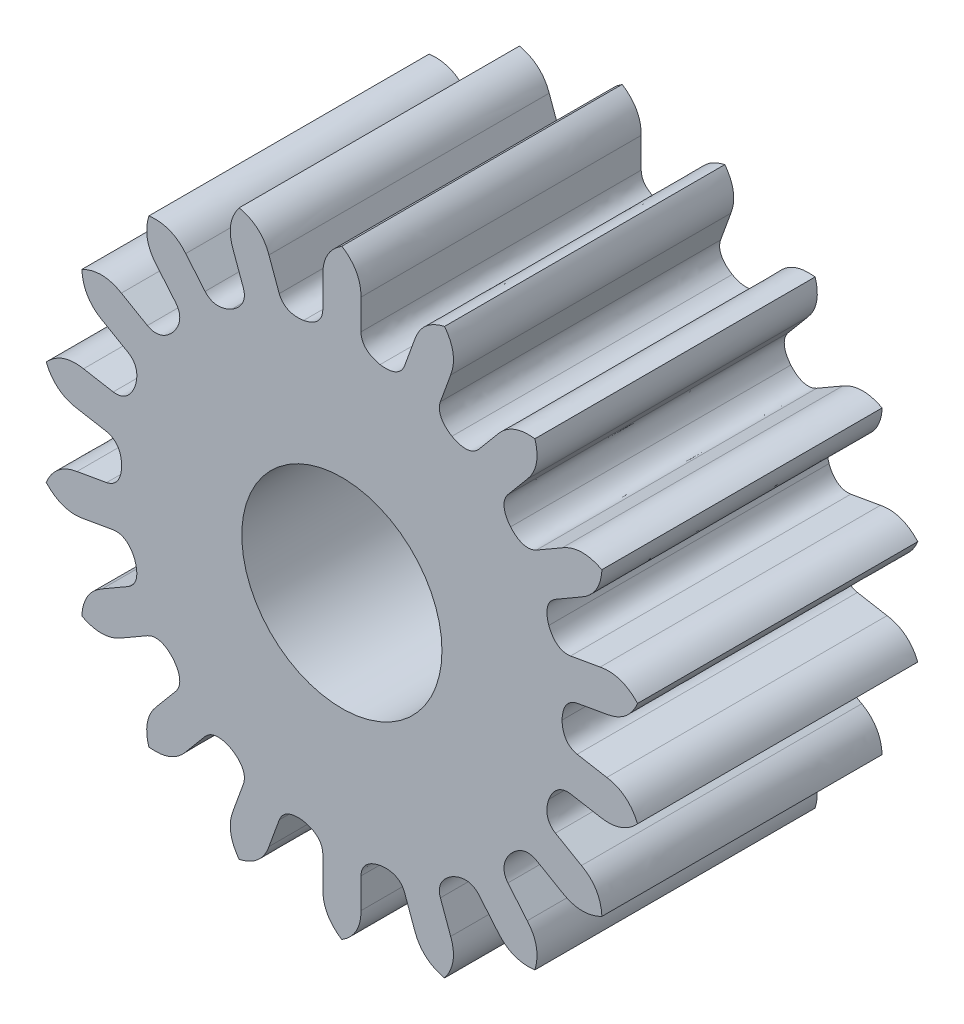
from build123d import *

# Parameters (mm, degrees)
BOSS_EXTRUDE1_18_TEETH_DEPTH = 1.4
CUT_EXTRUDE1_REACH           = 4.528
SKETCH2_R                    = 0.5


with BuildPart() as part:
    # Sketch1 → Boss-Extrude1 (18 teeth) (new body)
    with BuildSketch(Plane.XY):
        with BuildLine():
            Line((0.09535, 1.327125831), (0.09535, 1.176725832))
            add(Edge.make_bspline(
                [(0.09535, 1.176725832), (0.096898769, 1.121704145), (0.139449252, 1.093426583), (0.191012995, 1.083288528)],
                knots=[0, 0, 0, 0, 1, 1, 1, 1], degree=3))
            add(Edge.make_bspline(
                [(0.312864246, 1.138372202), (0.292590354, 1.087198438), (0.242934483, 1.075179344), (0.191012995, 1.083288528)],
                knots=[0, 0, 0, 0, 1, 1, 1, 1], degree=3))
            Line((0.312864246, 1.138372202), (0.364304075, 1.27970197))
            add(Edge.make_bspline(
                [(0.513010563, 1.409484937), (0.400738109, 1.383654504), (0.364304075, 1.27970197)],
                knots=[0, 0, 0, 1, 1, 1], degree=2))
            add(Edge.make_bspline(
                [(0.513010563, 1.409484937), (0.58241277, 1.317530335), (0.543503458, 1.214478729)],
                knots=[0, 0, 0, 1, 1, 1], degree=2))
            Line((0.543503458, 1.214478729), (0.492063629, 1.073148961))
            add(Edge.make_bspline(
                [(0.492063629, 1.073148961), (0.47470047, 1.020915777), (0.505013349, 0.979790438), (0.55, 0.952627944)],
                knots=[0, 0, 0, 0, 1, 1, 1, 1], degree=3))
            add(Edge.make_bspline(
                [(0.683342447, 0.962714083), (0.646788763, 0.921560555), (0.596016735, 0.927249609), (0.55, 0.952627944)],
                knots=[0, 0, 0, 0, 1, 1, 1, 1], degree=3))
            Line((0.683342447, 0.962714083), (0.780017703, 1.077927166))
            add(Edge.make_bspline(
                [(0.964144481, 1.149022649), (0.849808356, 1.163149422), (0.780017703, 1.077927166)],
                knots=[0, 0, 0, 1, 1, 1], degree=2))
            add(Edge.make_bspline(
                [(0.964144481, 1.149022649), (0.997910896, 1.038876635), (0.926102378, 0.955347569)],
                knots=[0, 0, 0, 1, 1, 1], degree=2))
            Line((0.926102378, 0.955347569), (0.829427123, 0.840134486))
            add(Edge.make_bspline(
                [(0.829427123, 0.840134486), (0.795246289, 0.796989899), (0.809665384, 0.747977106), (0.842648887, 0.707066371)],
                knots=[0, 0, 0, 0, 1, 1, 1, 1], degree=3))
            add(Edge.make_bspline(
                [(0.971399464, 0.670938438), (0.9229749, 0.644768868), (0.877210572, 0.667479886), (0.842648887, 0.707066371)],
                knots=[0, 0, 0, 0, 1, 1, 1, 1], degree=3))
            Line((0.971399464, 0.670938438), (1.101649683, 0.746138438))
            add(Edge.make_bspline(
                [(1.298988345, 0.749971271), (1.196379173, 0.802351353), (1.101649683, 0.746138438)],
                knots=[0, 0, 0, 1, 1, 1], degree=2))
            add(Edge.make_bspline(
                [(1.298988345, 0.749971271), (1.293046241, 0.63491908), (1.196999683, 0.580987393)],
                knots=[0, 0, 0, 1, 1, 1], degree=2))
            Line((1.196999683, 0.580987393), (1.066749464, 0.505787394))
            add(Edge.make_bspline(
                [(1.066749464, 0.505787394), (1.019873669, 0.476935277), (1.016659824, 0.425946697), (1.033661883, 0.376222158)],
                knots=[0, 0, 0, 0, 1, 1, 1, 1], degree=3))
            add(Edge.make_bspline(
                [(1.142291369, 0.298237716), (1.087836644, 0.290208539), (1.052599867, 0.327202238), (1.033661883, 0.376222158)],
                knots=[0, 0, 0, 0, 1, 1, 1, 1], degree=3))
            Line((1.142291369, 0.298237716), (1.290406453, 0.324354401))
            add(Edge.make_bspline(
                [(1.477155044, 0.260462289), (1.398649005, 0.344777869), (1.290406453, 0.324354401)],
                knots=[0, 0, 0, 1, 1, 1], degree=2))
            add(Edge.make_bspline(
                [(1.477155044, 0.260462289), (1.432221125, 0.154380914), (1.323521161, 0.136551563)],
                knots=[0, 0, 0, 1, 1, 1], degree=2))
            Line((1.323521161, 0.136551563), (1.175406077, 0.110434877))
            add(Edge.make_bspline(
                [(1.175406077, 0.110434877), (1.121489233, 0.099355222), (1.101030084, 0.052540829), (1.1, 0)],
                knots=[0, 0, 0, 0, 1, 1, 1, 1], degree=3))
            add(Edge.make_bspline(
                [(1.175406077, -0.110434877), (1.121489233, -0.099355222), (1.101030084, -0.052540829), (1.1, 0)],
                knots=[0, 0, 0, 0, 1, 1, 1, 1], degree=3))
            Line((1.175406077, -0.110434877), (1.323521161, -0.136551563))
            add(Edge.make_bspline(
                [(1.477155044, -0.260462289), (1.432221125, -0.154380914), (1.323521161, -0.136551563)],
                knots=[0, 0, 0, 1, 1, 1], degree=2))
            add(Edge.make_bspline(
                [(1.477155044, -0.260462289), (1.398649005, -0.344777869), (1.290406453, -0.324354401)],
                knots=[0, 0, 0, 1, 1, 1], degree=2))
            Line((1.290406453, -0.324354401), (1.142291369, -0.298237716))
            add(Edge.make_bspline(
                [(1.142291369, -0.298237716), (1.087836644, -0.290208539), (1.052599867, -0.327202238), (1.033661883, -0.376222158)],
                knots=[0, 0, 0, 0, 1, 1, 1, 1], degree=3))
            add(Edge.make_bspline(
                [(1.066749464, -0.505787394), (1.019873669, -0.476935277), (1.016659824, -0.425946697), (1.033661883, -0.376222158)],
                knots=[0, 0, 0, 0, 1, 1, 1, 1], degree=3))
            Line((1.066749464, -0.505787394), (1.196999683, -0.580987393))
            add(Edge.make_bspline(
                [(1.298988345, -0.749971271), (1.293046241, -0.63491908), (1.196999683, -0.580987393)],
                knots=[0, 0, 0, 1, 1, 1], degree=2))
            add(Edge.make_bspline(
                [(1.298988345, -0.749971271), (1.196379173, -0.802351353), (1.101649683, -0.746138438)],
                knots=[0, 0, 0, 1, 1, 1], degree=2))
            Line((1.101649683, -0.746138438), (0.971399464, -0.670938438))
            add(Edge.make_bspline(
                [(0.971399464, -0.670938438), (0.9229749, -0.644768868), (0.877210572, -0.667479886), (0.842648887, -0.707066371)],
                knots=[0, 0, 0, 0, 1, 1, 1, 1], degree=3))
            add(Edge.make_bspline(
                [(0.829427123, -0.840134486), (0.795246289, -0.796989899), (0.809665384, -0.747977106), (0.842648887, -0.707066371)],
                knots=[0, 0, 0, 0, 1, 1, 1, 1], degree=3))
            Line((0.829427123, -0.840134486), (0.926102378, -0.955347569))
            add(Edge.make_bspline(
                [(0.964144481, -1.149022649), (0.997910896, -1.038876635), (0.926102378, -0.955347569)],
                knots=[0, 0, 0, 1, 1, 1], degree=2))
            add(Edge.make_bspline(
                [(0.964144481, -1.149022649), (0.849808356, -1.163149422), (0.780017703, -1.077927166)],
                knots=[0, 0, 0, 1, 1, 1], degree=2))
            Line((0.780017703, -1.077927166), (0.683342447, -0.962714083))
            add(Edge.make_bspline(
                [(0.683342447, -0.962714083), (0.646788763, -0.921560555), (0.596016735, -0.927249609), (0.55, -0.952627944)],
                knots=[0, 0, 0, 0, 1, 1, 1, 1], degree=3))
            add(Edge.make_bspline(
                [(0.492063629, -1.073148961), (0.47470047, -1.020915777), (0.505013349, -0.979790438), (0.55, -0.952627944)],
                knots=[0, 0, 0, 0, 1, 1, 1, 1], degree=3))
            Line((0.492063629, -1.073148961), (0.543503458, -1.214478729))
            add(Edge.make_bspline(
                [(0.513010563, -1.409484937), (0.58241277, -1.317530335), (0.543503458, -1.214478729)],
                knots=[0, 0, 0, 1, 1, 1], degree=2))
            add(Edge.make_bspline(
                [(0.513010563, -1.409484937), (0.400738109, -1.383654504), (0.364304075, -1.27970197)],
                knots=[0, 0, 0, 1, 1, 1], degree=2))
            Line((0.364304075, -1.27970197), (0.312864246, -1.138372202))
            add(Edge.make_bspline(
                [(0.312864246, -1.138372202), (0.292590354, -1.087198438), (0.242934483, -1.075179344), (0.191012995, -1.083288528)],
                knots=[0, 0, 0, 0, 1, 1, 1, 1], degree=3))
            add(Edge.make_bspline(
                [(0.09535, -1.176725832), (0.096898769, -1.121704145), (0.139449252, -1.093426583), (0.191012995, -1.083288528)],
                knots=[0, 0, 0, 0, 1, 1, 1, 1], degree=3))
            Line((0.09535, -1.176725832), (0.09535, -1.327125831))
            add(Edge.make_bspline(
                [(0, -1.499942541), (0.096667068, -1.437270433), (0.09535, -1.327125831)],
                knots=[0, 0, 0, 1, 1, 1], degree=2))
            add(Edge.make_bspline(
                [(0, -1.499942541), (-0.096667068, -1.437270433), (-0.09535, -1.327125831)],
                knots=[0, 0, 0, 1, 1, 1], degree=2))
            Line((-0.09535, -1.327125831), (-0.09535, -1.176725832))
            add(Edge.make_bspline(
                [(-0.09535, -1.176725832), (-0.096898769, -1.121704145), (-0.139449252, -1.093426583), (-0.191012995, -1.083288528)],
                knots=[0, 0, 0, 0, 1, 1, 1, 1], degree=3))
            add(Edge.make_bspline(
                [(-0.312864246, -1.138372202), (-0.292590354, -1.087198438), (-0.242934483, -1.075179344), (-0.191012995, -1.083288528)],
                knots=[0, 0, 0, 0, 1, 1, 1, 1], degree=3))
            Line((-0.312864246, -1.138372202), (-0.364304075, -1.27970197))
            add(Edge.make_bspline(
                [(-0.513010563, -1.409484937), (-0.400738109, -1.383654504), (-0.364304075, -1.27970197)],
                knots=[0, 0, 0, 1, 1, 1], degree=2))
            add(Edge.make_bspline(
                [(-0.513010563, -1.409484937), (-0.58241277, -1.317530335), (-0.543503458, -1.214478729)],
                knots=[0, 0, 0, 1, 1, 1], degree=2))
            Line((-0.543503458, -1.214478729), (-0.492063629, -1.073148961))
            add(Edge.make_bspline(
                [(-0.492063629, -1.073148961), (-0.47470047, -1.020915777), (-0.505013349, -0.979790438), (-0.55, -0.952627944)],
                knots=[0, 0, 0, 0, 1, 1, 1, 1], degree=3))
            add(Edge.make_bspline(
                [(-0.683342447, -0.962714083), (-0.646788763, -0.921560555), (-0.596016735, -0.927249609), (-0.55, -0.952627944)],
                knots=[0, 0, 0, 0, 1, 1, 1, 1], degree=3))
            Line((-0.683342447, -0.962714083), (-0.780017703, -1.077927166))
            add(Edge.make_bspline(
                [(-0.964144481, -1.149022649), (-0.849808356, -1.163149422), (-0.780017703, -1.077927166)],
                knots=[0, 0, 0, 1, 1, 1], degree=2))
            add(Edge.make_bspline(
                [(-0.964144481, -1.149022649), (-0.997910896, -1.038876635), (-0.926102378, -0.955347569)],
                knots=[0, 0, 0, 1, 1, 1], degree=2))
            Line((-0.926102378, -0.955347569), (-0.829427123, -0.840134486))
            add(Edge.make_bspline(
                [(-0.829427123, -0.840134486), (-0.795246289, -0.796989899), (-0.809665384, -0.747977106), (-0.842648887, -0.707066371)],
                knots=[0, 0, 0, 0, 1, 1, 1, 1], degree=3))
            add(Edge.make_bspline(
                [(-0.971399464, -0.670938438), (-0.9229749, -0.644768868), (-0.877210572, -0.667479886), (-0.842648887, -0.707066371)],
                knots=[0, 0, 0, 0, 1, 1, 1, 1], degree=3))
            Line((-0.971399464, -0.670938438), (-1.101649683, -0.746138438))
            add(Edge.make_bspline(
                [(-1.298988345, -0.749971271), (-1.196379173, -0.802351353), (-1.101649683, -0.746138438)],
                knots=[0, 0, 0, 1, 1, 1], degree=2))
            add(Edge.make_bspline(
                [(-1.298988345, -0.749971271), (-1.293046241, -0.63491908), (-1.196999683, -0.580987393)],
                knots=[0, 0, 0, 1, 1, 1], degree=2))
            Line((-1.196999683, -0.580987393), (-1.066749464, -0.505787394))
            add(Edge.make_bspline(
                [(-1.066749464, -0.505787394), (-1.019873669, -0.476935277), (-1.016659824, -0.425946697), (-1.033661883, -0.376222158)],
                knots=[0, 0, 0, 0, 1, 1, 1, 1], degree=3))
            add(Edge.make_bspline(
                [(-1.142291369, -0.298237716), (-1.087836644, -0.290208539), (-1.052599867, -0.327202238), (-1.033661883, -0.376222158)],
                knots=[0, 0, 0, 0, 1, 1, 1, 1], degree=3))
            Line((-1.142291369, -0.298237716), (-1.290406453, -0.324354401))
            add(Edge.make_bspline(
                [(-1.477155044, -0.260462289), (-1.398649005, -0.344777869), (-1.290406453, -0.324354401)],
                knots=[0, 0, 0, 1, 1, 1], degree=2))
            add(Edge.make_bspline(
                [(-1.477155044, -0.260462289), (-1.432221125, -0.154380914), (-1.323521161, -0.136551563)],
                knots=[0, 0, 0, 1, 1, 1], degree=2))
            Line((-1.323521161, -0.136551563), (-1.175406077, -0.110434877))
            add(Edge.make_bspline(
                [(-1.175406077, -0.110434877), (-1.121489233, -0.099355222), (-1.101030084, -0.052540829), (-1.1, 0)],
                knots=[0, 0, 0, 0, 1, 1, 1, 1], degree=3))
            add(Edge.make_bspline(
                [(-1.175406077, 0.110434877), (-1.121489233, 0.099355222), (-1.101030084, 0.052540829), (-1.1, 0)],
                knots=[0, 0, 0, 0, 1, 1, 1, 1], degree=3))
            Line((-1.175406077, 0.110434877), (-1.323521161, 0.136551563))
            add(Edge.make_bspline(
                [(-1.477155044, 0.260462289), (-1.432221125, 0.154380914), (-1.323521161, 0.136551563)],
                knots=[0, 0, 0, 1, 1, 1], degree=2))
            add(Edge.make_bspline(
                [(-1.477155044, 0.260462289), (-1.398649005, 0.344777869), (-1.290406453, 0.324354401)],
                knots=[0, 0, 0, 1, 1, 1], degree=2))
            Line((-1.290406453, 0.324354401), (-1.142291369, 0.298237716))
            add(Edge.make_bspline(
                [(-1.142291369, 0.298237716), (-1.087836644, 0.290208539), (-1.052599867, 0.327202238), (-1.033661883, 0.376222158)],
                knots=[0, 0, 0, 0, 1, 1, 1, 1], degree=3))
            add(Edge.make_bspline(
                [(-1.066749464, 0.505787394), (-1.019873669, 0.476935277), (-1.016659824, 0.425946697), (-1.033661883, 0.376222158)],
                knots=[0, 0, 0, 0, 1, 1, 1, 1], degree=3))
            Line((-1.066749464, 0.505787394), (-1.196999683, 0.580987393))
            add(Edge.make_bspline(
                [(-1.298988345, 0.749971271), (-1.293046241, 0.63491908), (-1.196999683, 0.580987393)],
                knots=[0, 0, 0, 1, 1, 1], degree=2))
            add(Edge.make_bspline(
                [(-1.298988345, 0.749971271), (-1.196379173, 0.802351353), (-1.101649683, 0.746138438)],
                knots=[0, 0, 0, 1, 1, 1], degree=2))
            Line((-1.101649683, 0.746138438), (-0.971399464, 0.670938438))
            add(Edge.make_bspline(
                [(-0.971399464, 0.670938438), (-0.9229749, 0.644768868), (-0.877210572, 0.667479886), (-0.842648887, 0.707066371)],
                knots=[0, 0, 0, 0, 1, 1, 1, 1], degree=3))
            add(Edge.make_bspline(
                [(-0.829427123, 0.840134486), (-0.795246289, 0.796989899), (-0.809665384, 0.747977106), (-0.842648887, 0.707066371)],
                knots=[0, 0, 0, 0, 1, 1, 1, 1], degree=3))
            Line((-0.829427123, 0.840134486), (-0.926102378, 0.955347569))
            add(Edge.make_bspline(
                [(-0.964144481, 1.149022649), (-0.997910896, 1.038876635), (-0.926102378, 0.955347569)],
                knots=[0, 0, 0, 1, 1, 1], degree=2))
            add(Edge.make_bspline(
                [(-0.964144481, 1.149022649), (-0.849808356, 1.163149422), (-0.780017703, 1.077927166)],
                knots=[0, 0, 0, 1, 1, 1], degree=2))
            Line((-0.780017703, 1.077927166), (-0.683342447, 0.962714083))
            add(Edge.make_bspline(
                [(-0.683342447, 0.962714083), (-0.646788763, 0.921560555), (-0.596016735, 0.927249609), (-0.55, 0.952627944)],
                knots=[0, 0, 0, 0, 1, 1, 1, 1], degree=3))
            add(Edge.make_bspline(
                [(-0.492063629, 1.073148961), (-0.47470047, 1.020915777), (-0.505013349, 0.979790438), (-0.55, 0.952627944)],
                knots=[0, 0, 0, 0, 1, 1, 1, 1], degree=3))
            Line((-0.492063629, 1.073148961), (-0.543503458, 1.214478729))
            add(Edge.make_bspline(
                [(-0.513010563, 1.409484937), (-0.58241277, 1.317530335), (-0.543503458, 1.214478729)],
                knots=[0, 0, 0, 1, 1, 1], degree=2))
            add(Edge.make_bspline(
                [(-0.513010563, 1.409484937), (-0.400738109, 1.383654504), (-0.364304075, 1.27970197)],
                knots=[0, 0, 0, 1, 1, 1], degree=2))
            Line((-0.364304075, 1.27970197), (-0.312864246, 1.138372202))
            add(Edge.make_bspline(
                [(-0.312864246, 1.138372202), (-0.292590354, 1.087198438), (-0.242934483, 1.075179344), (-0.191012995, 1.083288528)],
                knots=[0, 0, 0, 0, 1, 1, 1, 1], degree=3))
            add(Edge.make_bspline(
                [(-0.09535, 1.176725832), (-0.096898769, 1.121704145), (-0.139449252, 1.093426583), (-0.191012995, 1.083288528)],
                knots=[0, 0, 0, 0, 1, 1, 1, 1], degree=3))
            Line((-0.09535, 1.176725832), (-0.09535, 1.327125831))
            add(Edge.make_bspline(
                [(0, 1.499942541), (-0.096667068, 1.437270433), (-0.09535, 1.327125831)],
                knots=[0, 0, 0, 1, 1, 1], degree=2))
            add(Edge.make_bspline(
                [(0, 1.499942541), (0.096667068, 1.437270433), (0.09535, 1.327125831)],
                knots=[0, 0, 0, 1, 1, 1], degree=2))
        make_face()
    extrude(amount=BOSS_EXTRUDE1_18_TEETH_DEPTH)

    # Sketch2 → Cut-Extrude1 (cut, up to next)
    with BuildSketch(Plane.XY, mode=Mode.PRIVATE) as cut_extrude1_sk1:
        Circle(SKETCH2_R)
    cut_extrude1_tool1 = extrude(cut_extrude1_sk1.sketch, amount=CUT_EXTRUDE1_REACH, mode=Mode.PRIVATE) & part.part
    add(cut_extrude1_tool1.solids().sort_by_distance((0, 0, 0))[0], mode=Mode.SUBTRACT)


solid = part.part
